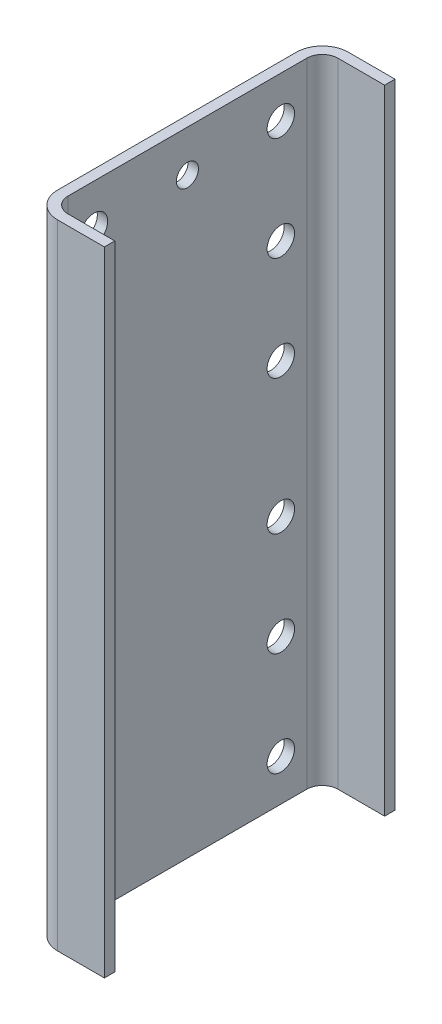
from build123d import *

# Parameters (mm, degrees)
BASE_EXTRUDE_DEPTH      = 193.675
BASE_EXTRUDE_DEPTH_BACK = 193.675
SKETCH2_R               = 8.382
SKETCH2_R_2             = 6.731
HOLES_DEPTH             = 218.690188399


with BuildPart() as part:
    # Sketch1 → Base-Extrude (new, two sides: drawn at the far end of the back side and taken through both)
    with BuildSketch(Plane(origin=(0, 0, 0), x_dir=(0, 0, -1), z_dir=(0, 1, 0)).offset(-BASE_EXTRUDE_DEPTH_BACK)):
        with BuildLine():
            Line((-73.025, 0), (73.025, 0))
            ThreePointArc((73.025, 0), (84.250320151, -4.649679849), (88.9, -15.875))
            Line((88.9, -15.875), (88.9, -44.45))
            Line((88.9, -44.45), (82.55, -44.45))
            Line((82.55, -44.45), (82.55, -15.875))
            ThreePointArc((82.55, -15.875), (79.760192091, -9.139807909), (73.025, -6.35))
            Line((73.025, -6.35), (-73.025, -6.35))
            ThreePointArc((-73.025, -6.35), (-79.760192091, -9.139807909), (-82.55, -15.875))
            Line((-82.55, -15.875), (-82.55, -44.45))
            Line((-82.55, -44.45), (-88.9, -44.45))
            Line((-88.9, -44.45), (-88.9, -15.875))
            ThreePointArc((-88.9, -15.875), (-84.250320151, -4.649679849), (-73.025, 0))
        make_face()
    extrude(amount=BASE_EXTRUDE_DEPTH + BASE_EXTRUDE_DEPTH_BACK)

    # Sketch2 → Holes (cut, through all)
    with BuildSketch(Plane(origin=(0, 0, 0), x_dir=(0, 0, -1), z_dir=(1, 0, 0))):
        with Locations((57.15, 41.275)):
            Circle(SKETCH2_R)
        with Locations((57.15, 104.775)):
            Circle(SKETCH2_R)
        with Locations((57.15, 168.275)):
            Circle(SKETCH2_R)
        with Locations((57.15, -41.275)):
            Circle(SKETCH2_R)
        with Locations((57.15, -104.775)):
            Circle(SKETCH2_R)
        with Locations((57.15, -168.275)):
            Circle(SKETCH2_R)
        with Locations((-57.15, -168.275)):
            Circle(SKETCH2_R)
        with Locations((-57.15, -104.775)):
            Circle(SKETCH2_R)
        with Locations((-57.15, -41.275)):
            Circle(SKETCH2_R)
        with Locations((-57.15, 41.275)):
            Circle(SKETCH2_R)
        with Locations((-57.15, 104.775)):
            Circle(SKETCH2_R)
        with Locations((-57.15, 168.275)):
            Circle(SKETCH2_R)
        with Locations((0, 168.275)):
            Circle(SKETCH2_R_2)
    extrude(amount=HOLES_DEPTH, mode=Mode.SUBTRACT)


solid = part.part
